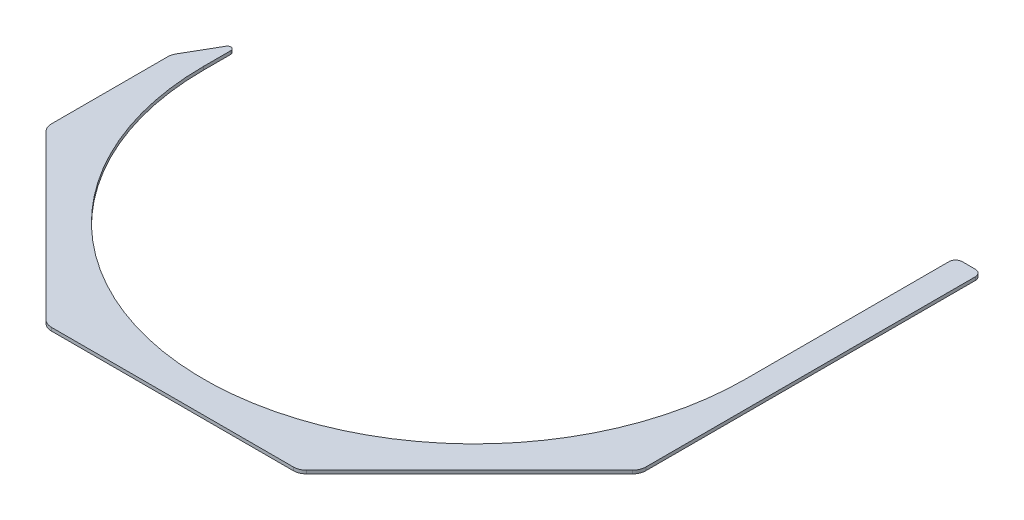
from build123d import *

# Parameters (mm, degrees)
BOSS_EXTRUDE1_DEPTH = 3.175
FILLET1_R           = 3.175
CUT_EXTRUDE1_DEPTH  = 4.175
FILLET2_R           = 12.7
FILLET3_R           = 6.35


with BuildPart() as part:
    # Sketch1 → Boss-Extrude1 (new body)
    with BuildSketch(Plane(origin=(0, 0, 0), x_dir=(1, 0, 0), z_dir=(0, 1, 0))):
        with BuildLine():
            Line((-287.3375, -5.894090512), (-287.3375, -292.1))
            Line((-287.3375, -292.1), (287.3375, -292.1))
            Line((287.3375, -292.1), (287.3375, 203.2))
            Line((287.3375, 203.2), (261.9375, 203.2))
            Line((261.9375, 203.2), (261.9375, 0))
            ThreePointArc((261.9375, 0), (0, -261.9375), (-261.9375, 0))
            Line((-261.9375, 0), (-261.9375, 38.1))
            Line((-261.9375, 38.1), (-287.3375, -5.894090512))
        make_face()
    extrude(amount=BOSS_EXTRUDE1_DEPTH)

    # Fillet1
    fillet1_edges = [part.edges().sort_by_distance(p)[0] for p in [
        (-261.9375, 1.5875, -38.1),
    ]]
    fillet(fillet1_edges, radius=FILLET1_R)

    # Sketch2 → Cut-Extrude1 (cut, through all)
    with BuildSketch(Plane(origin=(0, 3.175, 0), x_dir=(1, 0, 0), z_dir=(0, 1, 0))):
        Polygon((287.3375, -292.1), (122.2375, -292.1), (287.3375, -127), align=None)
        Polygon((-287.3375, -292.1), (-122.2375, -292.1), (-287.3375, -127), align=None)
    extrude(amount=-CUT_EXTRUDE1_DEPTH, mode=Mode.SUBTRACT)

    # Fillet2
    fillet2_edges = [part.edges().sort_by_distance(p)[0] for p in [
        (-287.3375, 1.5875, 5.894090512),
        (287.3375, 1.5875, 127),
        (122.2375, 1.5875, 292.1),
        (-287.3375, 1.5875, 127),
        (-122.2375, 1.5875, 292.1),
    ]]
    fillet(fillet2_edges, radius=FILLET2_R)

    # Fillet3
    fillet3_edges = [part.edges().sort_by_distance(p)[0] for p in [
        (261.9375, 1.5875, -203.2),
        (287.3375, 1.5875, -203.2),
    ]]
    fillet(fillet3_edges, radius=FILLET3_R)


solid = part.part
